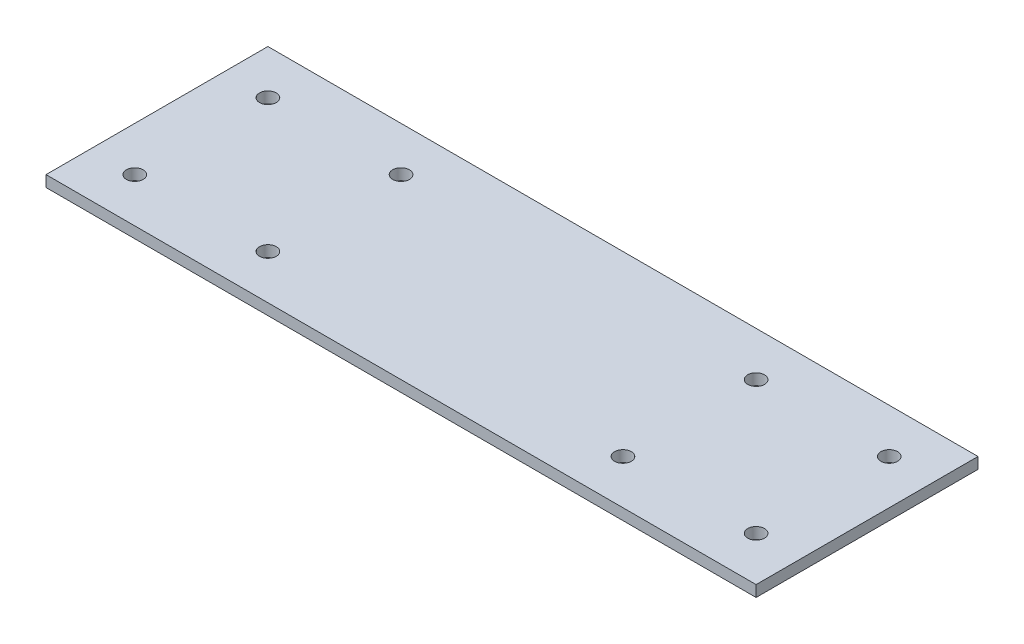
from build123d import *

# Parameters (mm, degrees)
SKETCH1_W            = 101.6
SKETCH1_H            = 31.75
BOSS_EXTRUDE1_DEPTH  = 1.6002
M2_CLEARANCE_HOLE1_D = 2.4


with BuildPart() as part:
    # Sketch1 → Boss-Extrude1 (new body)
    with BuildSketch(Plane(origin=(0, 0, 0), x_dir=(1, 0, 0), z_dir=(0, 1, 0))):
        Rectangle(SKETCH1_W, SKETCH1_H)
    extrude(amount=BOSS_EXTRUDE1_DEPTH)

    # M2 Clearance Hole1 (through all)
    with Locations(Plane(origin=(0, 1.6002, 0), x_dir=(1, 0, 0), z_dir=(0, 1, 0))):
        with Locations((-25.4, 9.525), (-44.45, 9.525), (-44.45, -9.525), (-25.4, -9.525)):
            m2_clearance_hole1 = Hole(M2_CLEARANCE_HOLE1_D / 2)

    # Mirror1: M2 Clearance Hole1 across plane
    add(m2_clearance_hole1.mirror(Plane(origin=(0, 0, 0), x_dir=(0, 0, 1), z_dir=(1, 0, 0))), mode=Mode.SUBTRACT)


solid = part.part
